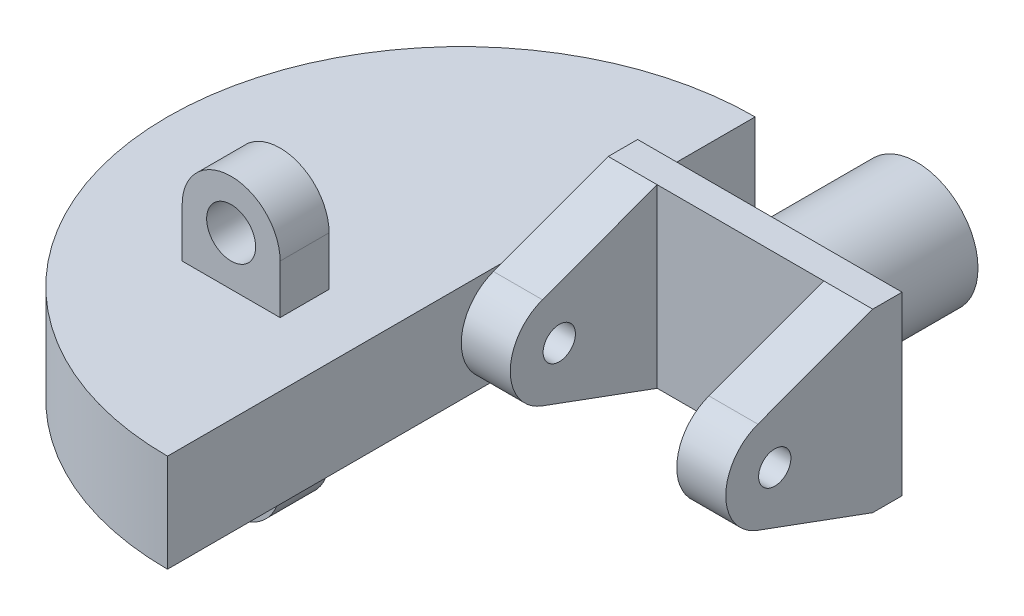
from build123d import *

# Parameters (mm, degrees)
SKETCH_1_R      = 6.25
EXTRUDE_1_DEPTH = 15
SKETCH_2_W      = 27
SKETCH_2_H      = 18
EXTRUDE_2_DEPTH = 3
EXTRUDE_START   = 13.5
SKETCH_3_R      = 1.65
EXTRUDE_3_DEPTH = 5
EXTRUDE_START_2 = -13.5
SKETCH_3_2_R    = 1.65
EXTRUDE_4_DEPTH = 5
EXTRUDE_5_DEPTH = 5
SKETCH_5_R      = 2.5
EXTRUDE_6_DEPTH = 5


with BuildPart() as part:
    # ｽｹｯﾁ1 → ﾎﾞｽ - 押し出し1 (new body)
    with BuildSketch(Plane.XY):
        Circle(SKETCH_1_R)
    extrude(amount=EXTRUDE_1_DEPTH)

    # ｽｹｯﾁ2 → ﾎﾞｽ - 押し出し2 (add)
    with BuildSketch(Plane.XY.offset(15)):
        Rectangle(SKETCH_2_W, SKETCH_2_H)
    extrude(amount=EXTRUDE_2_DEPTH)

    # ｽｹｯﾁ3 → ﾎﾞｽ - 押し出し3 (add)
    with BuildSketch(Plane(origin=(0, 0, 0), x_dir=(0, 0, -1), z_dir=(1, 0, 0)).offset(EXTRUDE_START)):
        with BuildLine():
            Line((-18, 9), (-29.724032154, 4.69336906))
            ThreePointArc((-29.724032154, 4.69336906), (-33, 0), (-29.724032154, -4.69336906))
            Line((-29.724032154, -4.69336906), (-18, -9))
            Line((-18, -9), (-18, 9))
        make_face()
        with Locations((-28, 0)):
            Circle(SKETCH_3_R, mode=Mode.SUBTRACT)
    extrude(amount=-EXTRUDE_3_DEPTH)

    # ｽｹｯﾁ3<2> → ﾎﾞｽ - 押し出し4 (add)
    with BuildSketch(Plane(origin=(0, 0, 0), x_dir=(0, 0, -1), z_dir=(1, 0, 0)).offset(EXTRUDE_START_2)):
        with BuildLine():
            Line((-18, 9), (-29.724032154, 4.69336906))
            ThreePointArc((-29.724032154, 4.69336906), (-33, 0), (-29.724032154, -4.69336906))
            Line((-29.724032154, -4.69336906), (-18, -9))
            Line((-18, -9), (-18, 9))
        make_face()
        with Locations((-28, 0)):
            Circle(SKETCH_3_2_R, mode=Mode.SUBTRACT)
    extrude(amount=EXTRUDE_4_DEPTH)

    # ｽｹｯﾁ4 → ﾎﾞｽ - 押し出し5 (add, symmetric)
    with BuildSketch(Plane(origin=(0, 0, 0), x_dir=(1, 0, 0), z_dir=(0, 1, 0))):
        with BuildLine():
            Line((-13.5, -63), (-13.5, -3))
            ThreePointArc((-13.5, -3), (-43.5, -33), (-13.5, -63))
        make_face()
    extrude(amount=EXTRUDE_5_DEPTH, both=True)

    # ｽｹｯﾁ5 → ﾎﾞｽ - 押し出し6 (add)
    with BuildSketch(Plane.XY.offset(40)):
        with BuildLine():
            Line((-30, 5), (-30, 10))
            ThreePointArc((-30, 10), (-25, 15), (-20, 10))
            Line((-20, 10), (-20, 5))
            Line((-20, 5), (-30, 5))
        make_face()
        with Locations((-25, 10)):
            Circle(SKETCH_5_R, mode=Mode.SUBTRACT)
    extrude_6 = extrude(amount=EXTRUDE_6_DEPTH)

    # ﾐﾗｰ1: ﾎﾞｽ - 押し出し6 across plane
    add(extrude_6.mirror(Plane.ZX))


solid = part.part
